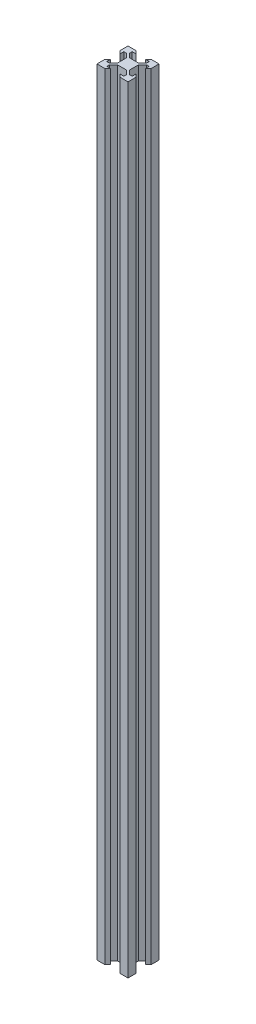
from build123d import *

# Parameters (mm, degrees)
BOSS_EXTRUDE1_DEPTH = 500


with BuildPart() as part:
    # Sketch1 → Boss-Extrude1 (new body)
    with BuildSketch(Plane(origin=(0, 0, 0), x_dir=(1, 0, 0), z_dir=(0, 1, 0))):
        Polygon((2.84, -3.900660172), (-2.84, -3.900660172), (-5.499339828, -6.56), (-5.499339828, -8.2), (-3.1, -8.2), (-4.9, -10), (-10, -10), (-10, -4.9), (-8.2, -3.1), (-8.2, -5.499339828), (-6.56, -5.499339828), (-3.900660172, -2.84), (-3.900660172, 2.84), (-6.56, 5.499339828), (-8.2, 5.499339828), (-8.2, 3.1), (-10, 4.9), (-10, 10), (-4.9, 10), (-3.1, 8.2), (-5.499339828, 8.2), (-5.499339828, 6.56), (-2.84, 3.900660172), (2.84, 3.900660172), (5.499339828, 6.56), (5.499339828, 8.2), (3.1, 8.2), (4.9, 10), (10, 10), (10, 4.9), (8.2, 3.1), (8.2, 5.499339828), (6.56, 5.499339828), (3.900660172, 2.84), (3.900660172, -2.84), (6.56, -5.499339828), (8.2, -5.499339828), (8.2, -3.1), (10, -4.9), (10, -10), (4.9, -10), (3.1, -8.2), (5.499339828, -8.2), (5.499339828, -6.56), align=None)
    extrude(amount=BOSS_EXTRUDE1_DEPTH)


solid = part.part
